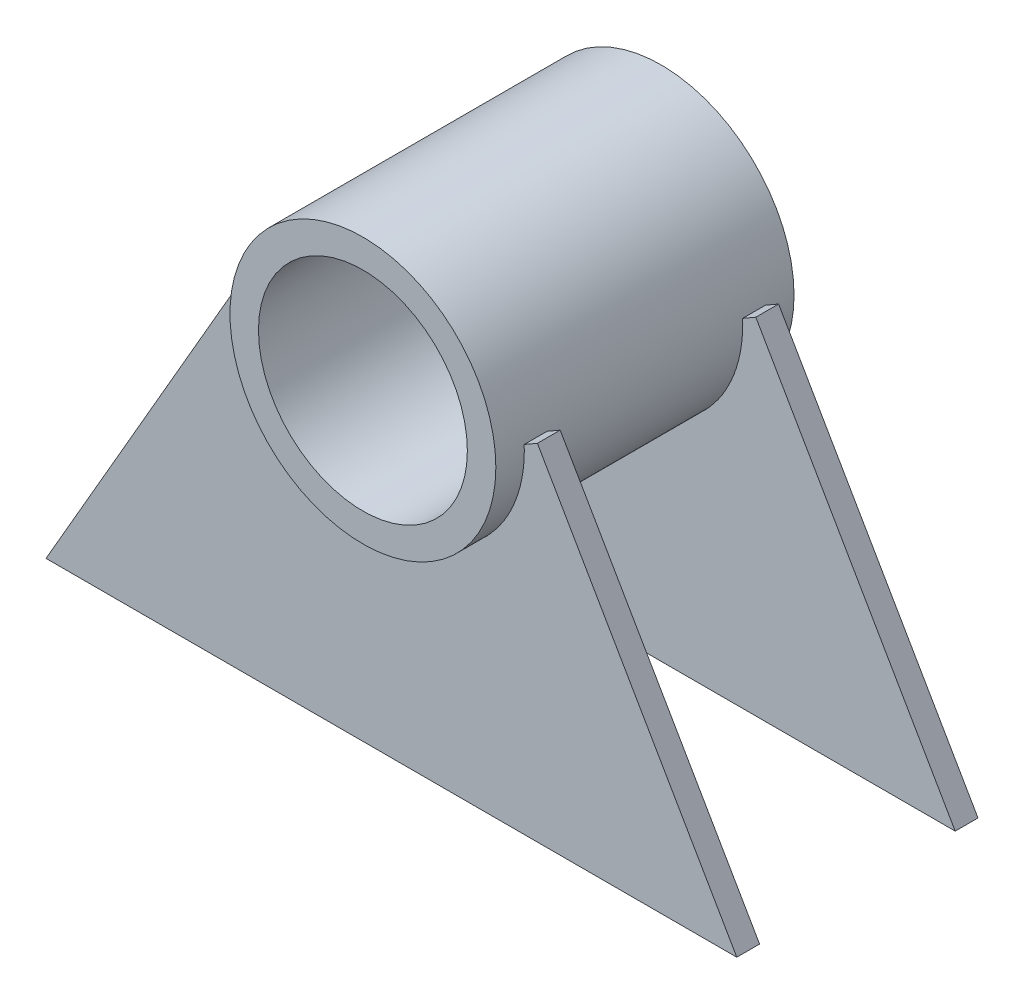
from build123d import *

# Parameters (mm, degrees)
SKETCH1_R                = 14
SKETCH1_R_2              = 11
BOSS_EXTRUDE1_DEPTH      = 15.7
BOSS_EXTRUDE1_DEPTH_BACK = 15.7
BOSS_EXTRUDE3_START      = 12.7
BOSS_EXTRUDE3_DEPTH      = 2.4
BOSS_EXTRUDE4_START      = -12.7
BOSS_EXTRUDE4_DEPTH      = 2.4


with BuildPart() as part:
    # Sketch1 → Boss-Extrude1 (new body, two sides)
    with BuildSketch(Plane.XY) as boss_extrude1_sk:
        Circle(SKETCH1_R)
        Circle(SKETCH1_R_2, mode=Mode.SUBTRACT)
    extrude(amount=BOSS_EXTRUDE1_DEPTH)
    extrude(boss_extrude1_sk.sketch, amount=-BOSS_EXTRUDE1_DEPTH_BACK)


with BuildPart() as body_2:
    # Sketch2 → Boss-Extrude3 (new body)
    with BuildSketch(Plane.XY.offset(BOSS_EXTRUDE3_START)):
        with BuildLine():
            Line((-36.373066959, -35), (36.373066959, -35))
            Line((36.373066959, -35), (15.373971015, 1.371501088))
            Line((15.373971015, 1.371501088), (13.988330369, 0.571501088))
            ThreePointArc((13.988330369, 0.571501088), (0, -14), (-13.988330369, 0.571501088))
            Line((-13.988330369, 0.571501088), (-15.373971015, 1.371501088))
            Line((-15.373971015, 1.371501088), (-36.373066959, -35))
        make_face()
    extrude(amount=-BOSS_EXTRUDE3_DEPTH)


with BuildPart() as body_3:
    # Sketch2_2 → Boss-Extrude4 (new body)
    with BuildSketch(Plane.XY.offset(BOSS_EXTRUDE4_START)):
        with BuildLine():
            Line((-36.373066959, -35), (36.373066959, -35))
            Line((36.373066959, -35), (15.373971015, 1.371501088))
            Line((15.373971015, 1.371501088), (13.988330369, 0.571501088))
            ThreePointArc((13.988330369, 0.571501088), (0, -14), (-13.988330369, 0.571501088))
            Line((-13.988330369, 0.571501088), (-15.373971015, 1.371501088))
            Line((-15.373971015, 1.371501088), (-36.373066959, -35))
        make_face()
    extrude(amount=BOSS_EXTRUDE4_DEPTH)


solid = Compound([part.part, body_2.part, body_3.part])
